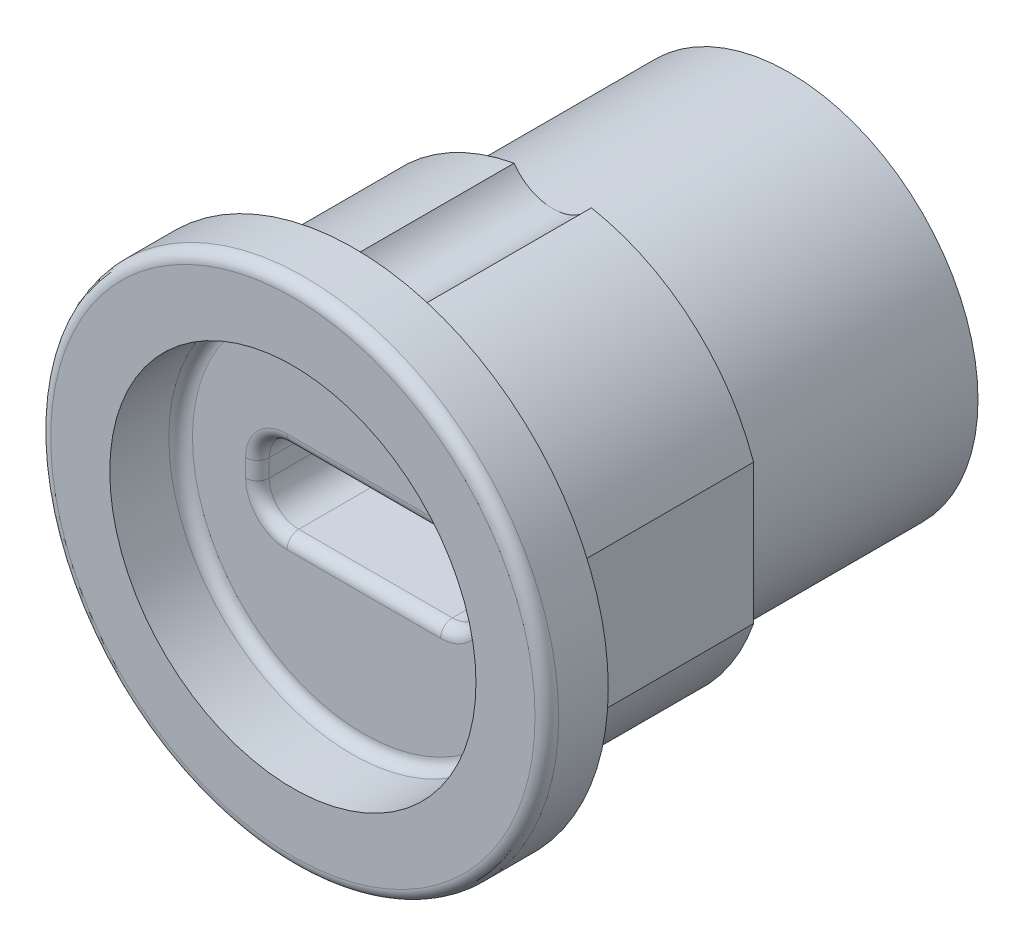
from build123d import *

# Parameters (mm, degrees)
SKETCH1_R           = 9
BOSS_EXTRUDE1_DEPTH = 18.4
SKETCH2_R           = 10.75
BOSS_EXTRUDE2_DEPTH = 2.6
SKETCH3_R           = 7.75
CUT_EXTRUDE1_DEPTH  = 3
SKETCH4_R           = 9
SKETCH4_R_2         = 8
CUT_EXTRUDE2_DEPTH  = 10
CUT_EXTRUDE3_DEPTH  = 8.4
CUT_EXTRUDE4_DEPTH  = 19.4
FILLET1_R           = 0.5


with BuildPart() as part:
    # Sketch1 → Boss-Extrude1 (new body)
    with BuildSketch(Plane.XY):
        Circle(SKETCH1_R)
    extrude(amount=-BOSS_EXTRUDE1_DEPTH)

    # Sketch2 → Boss-Extrude2 (add)
    with BuildSketch(Plane.XY):
        Circle(SKETCH2_R)
    extrude(amount=BOSS_EXTRUDE2_DEPTH)

    # Sketch3 → Cut-Extrude1 (cut)
    with BuildSketch(Plane.XY.offset(2.6)):
        Circle(SKETCH3_R)
    extrude(amount=-CUT_EXTRUDE1_DEPTH, mode=Mode.SUBTRACT)

    # Sketch4 → Cut-Extrude2 (cut)
    with BuildSketch(Plane(origin=(0, 0, -18.4), x_dir=(-1, 0, 0), z_dir=(0, 0, -1))):
        Circle(SKETCH4_R)
        Circle(SKETCH4_R_2, mode=Mode.SUBTRACT)
    extrude(amount=-CUT_EXTRUDE2_DEPTH, mode=Mode.SUBTRACT)

    # Sketch5 → Cut-Extrude3 (cut)
    with BuildSketch(Plane(origin=(0, 0, -8.4), x_dir=(-1, 0, 0), z_dir=(0, 0, -1))):
        with BuildLine():
            Line((-8.5, 2.958039892), (-8.5, -2.958039892))
            ThreePointArc((-8.5, -2.958039892), (-9, 0), (-8.5, 2.958039892))
        make_face()
        with BuildLine():
            Line((8.5, 2.958039892), (8.5, -2.958039892))
            ThreePointArc((8.5, -2.958039892), (9, 0), (8.5, 2.958039892))
        make_face()
        with BuildLine():
            ThreePointArc((-1.636306817, 8.85), (0, 8), (1.636306817, 8.85))
            ThreePointArc((1.636306817, 8.85), (0, 9), (-1.636306817, 8.85))
        make_face()
    extrude(amount=-CUT_EXTRUDE3_DEPTH, mode=Mode.SUBTRACT)

    # Sketch6 → Cut-Extrude4 (cut, through all)
    with BuildSketch(Plane.XY):
        with BuildLine():
            Line((-3.25, 1.625), (3.25, 1.625))
            ThreePointArc((3.25, 1.625), (4.133883476, 1.258883476), (4.5, 0.375))
            Line((4.5, 0.375), (4.5, -0.375))
            ThreePointArc((4.5, -0.375), (4.133883476, -1.258883476), (3.25, -1.625))
            Line((3.25, -1.625), (-3.25, -1.625))
            ThreePointArc((-3.25, -1.625), (-4.133883476, -1.258883476), (-4.5, -0.375))
            Line((-4.5, -0.375), (-4.5, 0.375))
            ThreePointArc((-4.5, 0.375), (-4.133883476, 1.258883476), (-3.25, 1.625))
        make_face()
    extrude(amount=-CUT_EXTRUDE4_DEPTH, mode=Mode.SUBTRACT)

    # Fillet1
    fillet1_edges = [part.edges().sort_by_distance(p)[0] for p in [
        (-7.75, 0, -0.4),
        (-4.133883476, 1.258883476, -0.4),
        (0, 1.625, -0.4),
        (4.133883476, 1.258883476, -0.4),
        (4.5, 0, -0.4),
        (4.133883476, -1.258883476, -0.4),
        (0, -1.625, -0.4),
        (-4.133883476, -1.258883476, -0.4),
        (-4.5, 0, -0.4),
        (-10.75, 0, 2.6),
    ]]
    fillet(fillet1_edges, radius=FILLET1_R)


solid = part.part
